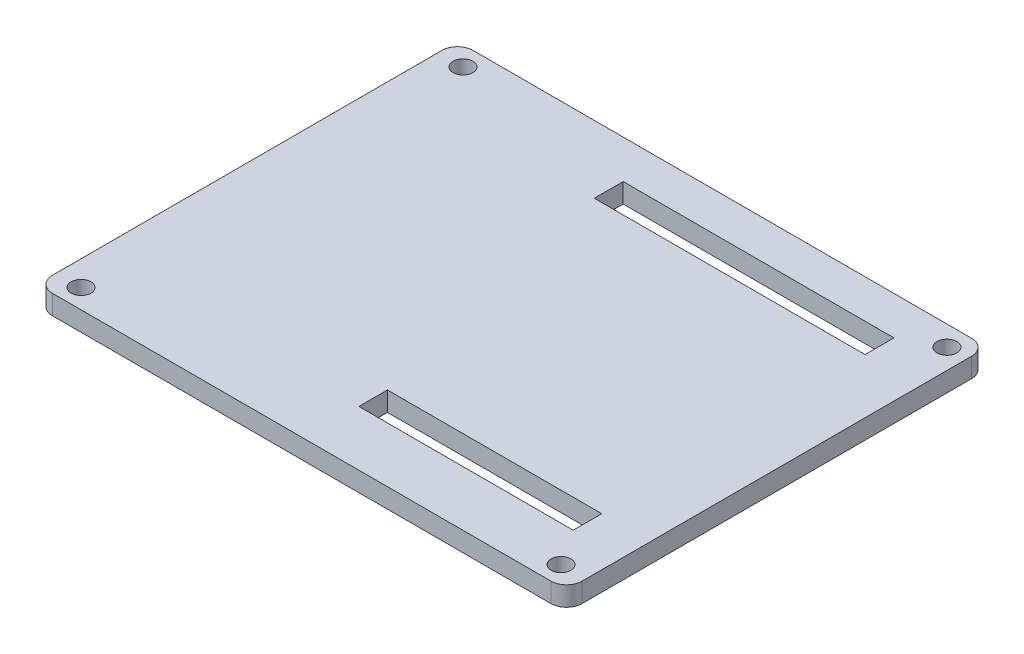
from build123d import *

# Parameters (mm, degrees)
SKETCH1_W           = 86.36
SKETCH1_H           = 68.58
BOSS_EXTRUDE1_DEPTH = 3.175
FILLET1_R           = 2.54
SKETCH2_R           = 1.6129
CUT_EXTRUDE1_DEPTH  = 4.175
SKETCH3_W           = 44.145937315
SKETCH3_H           = 4.712813079
SKETCH3_W_2         = 34.939039867
SKETCH3_H_2         = 4.658410012
CUT_EXTRUDE2_DEPTH  = 4.175


with BuildPart() as part:
    # Sketch1 → Boss-Extrude1 (new body)
    with BuildSketch(Plane(origin=(0, 0, 0), x_dir=(1, 0, 0), z_dir=(0, 1, 0))):
        with Locations((43.18, -34.29)):
            Rectangle(SKETCH1_W, SKETCH1_H)
    extrude(amount=BOSS_EXTRUDE1_DEPTH)

    # Fillet1
    fillet1_edges = [part.edges().sort_by_distance(p)[0] for p in [
        (0, 1.5875, 0),
        (86.36, 1.5875, 0),
        (86.36, 1.5875, 68.58),
        (0, 1.5875, 68.58),
    ]]
    fillet(fillet1_edges, radius=FILLET1_R)

    # Sketch2 → Cut-Extrude1 (cut, through all)
    with BuildSketch(Plane(origin=(0, 3.175, 0), x_dir=(-1, 0, 0), z_dir=(0, 1, 0))):
        with Locations(Location((-4.054045308, 3.152222292, 0), (0, 0, 90))):  # turned: the seam where the file's is
            Circle(SKETCH2_R)
        with Locations(Location((-83.076051224, 3.283948776, 0), (0, 0, 90))):  # turned: the seam where the file's is
            Circle(SKETCH2_R)
        with Locations(Location((-82.305954692, 65.427777708, 0), (0, 0, 90))):  # turned: the seam where the file's is
            Circle(SKETCH2_R)
        with Locations(Location((-4.054045308, 65.427777708, 0), (0, 0, 90))):  # turned: the seam where the file's is
            Circle(SKETCH2_R)
    extrude(amount=-CUT_EXTRUDE1_DEPTH, mode=Mode.SUBTRACT)

    # Sketch3 → Cut-Extrude2 (cut, through all)
    with BuildSketch(Plane(origin=(0, 3.175, 0), x_dir=(1, 0, 0), z_dir=(0, 1, 0))):
        with Locations((55.366118113, -8.634348767)):
            Rectangle(SKETCH3_W, SKETCH3_H)
        with Locations((60.97547331, -57.248737221)):
            Rectangle(SKETCH3_W_2, SKETCH3_H_2)
    extrude(amount=-CUT_EXTRUDE2_DEPTH, mode=Mode.SUBTRACT)


solid = part.part
